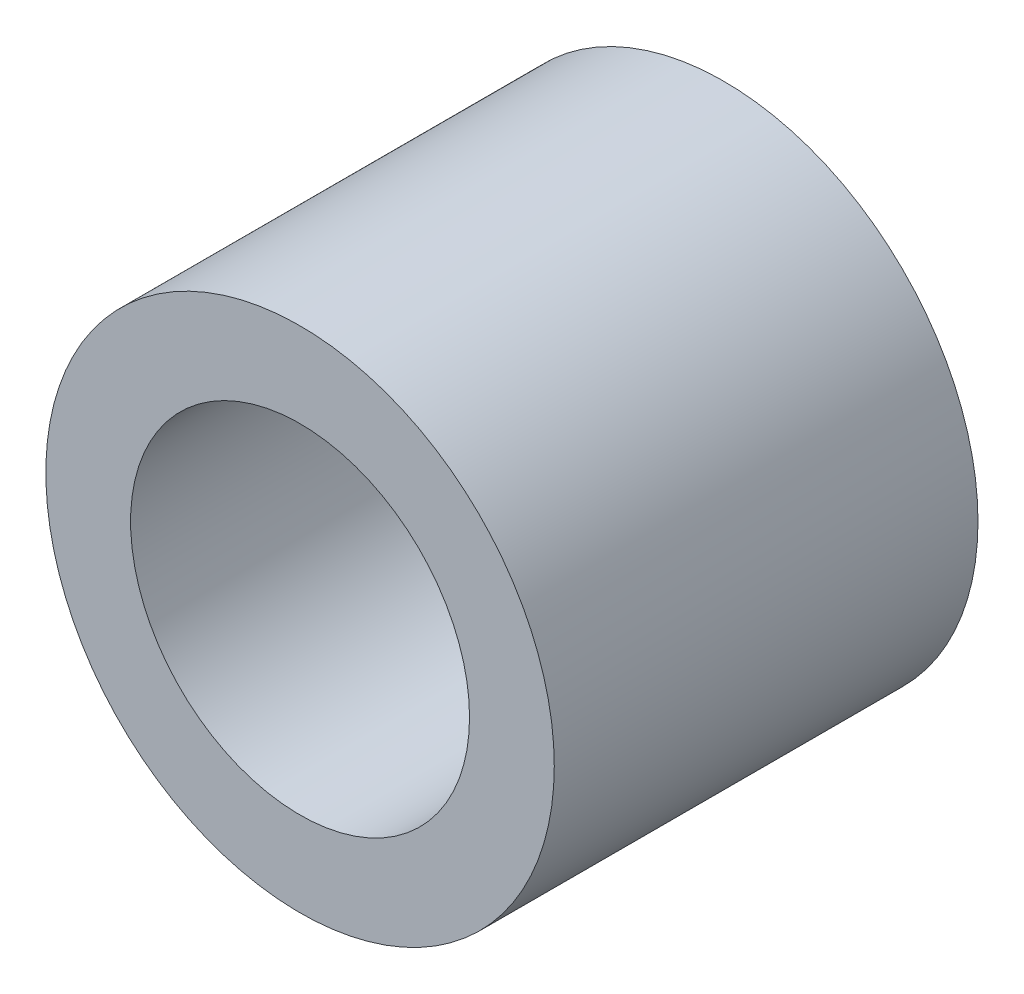
from build123d import *

# Parameters (mm, degrees)
SKETCH1_R           = 30
SKETCH1_R_2         = 20
BOSS_EXTRUDE2_DEPTH = 25


with BuildPart() as part:
    # Sketch1 → Boss-Extrude2 (new body, symmetric)
    with BuildSketch(Plane.XY):
        Circle(SKETCH1_R)
        Circle(SKETCH1_R_2, mode=Mode.SUBTRACT)
    extrude(amount=BOSS_EXTRUDE2_DEPTH, both=True)


solid = part.part
